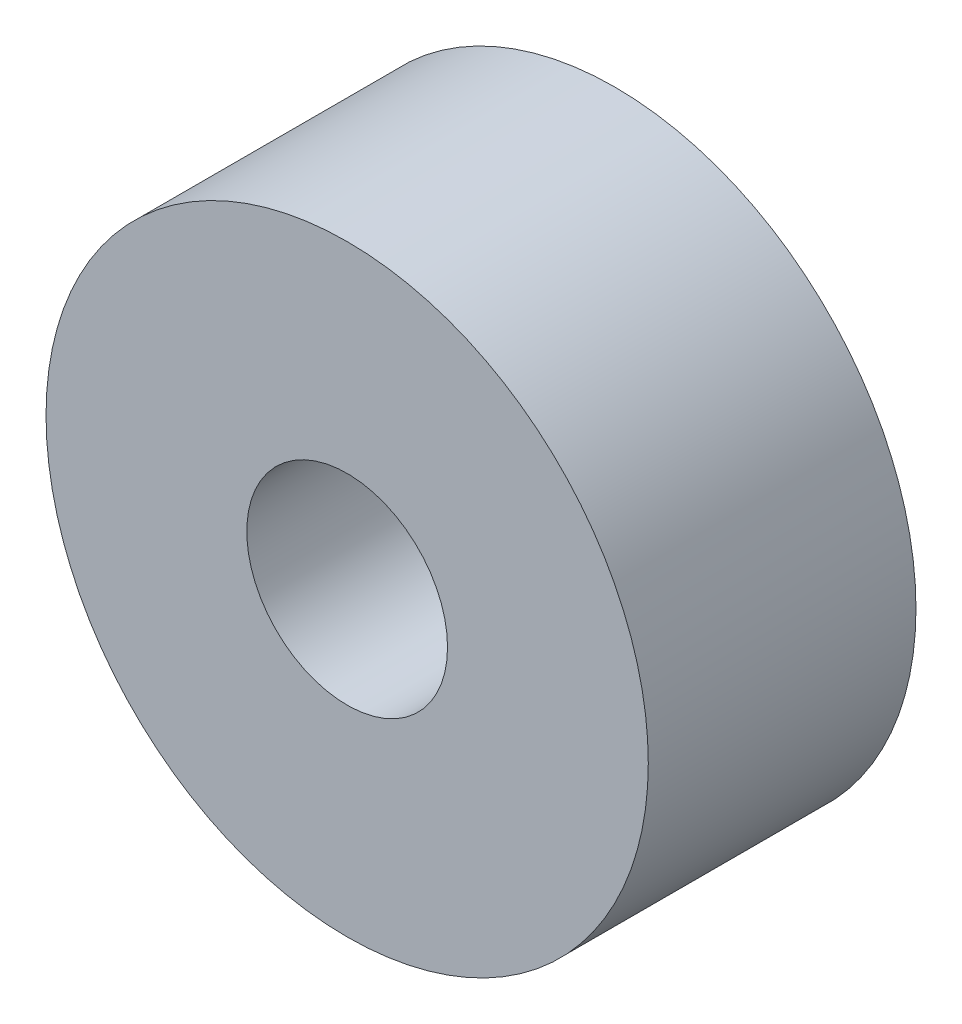
from build123d import *

# Parameters (mm, degrees)
SKETCH1_R           = 4.5
SKETCH1_R_2         = 1.5
BOSS_EXTRUDE1_DEPTH = 4


with BuildPart() as part:
    # Sketch1 → Boss-Extrude1 (new body)
    with BuildSketch(Plane.XY):
        Circle(SKETCH1_R)
        Circle(SKETCH1_R_2, mode=Mode.SUBTRACT)
    extrude(amount=BOSS_EXTRUDE1_DEPTH)


solid = part.part
